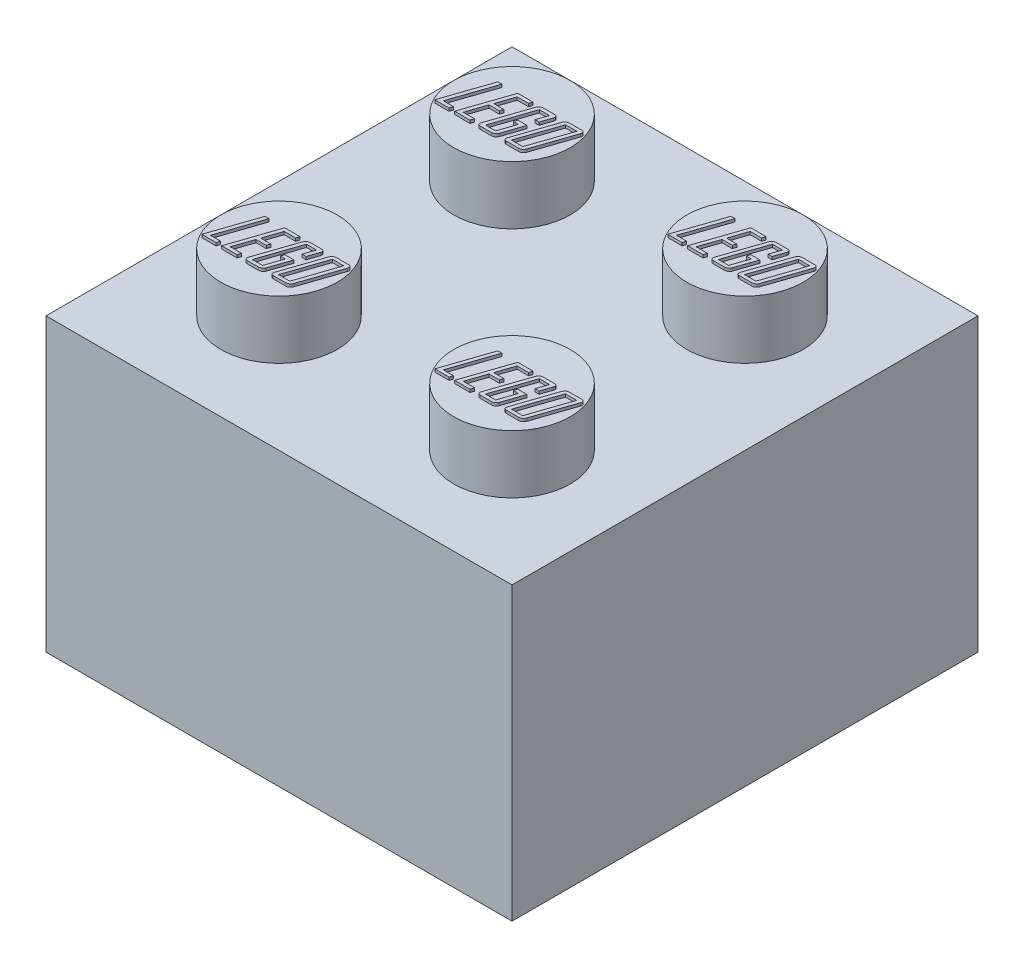
from build123d import *

# Parameters (mm, degrees)
SKETCH1_W           = 16
SKETCH1_H           = 16
BOSS_EXTRUDE1_DEPTH = 10
SKETCH2_R           = 2
BOSS_EXTRUDE2_DEPTH = 2
SHELL1_T            = -1
SKETCH3_R           = 2.7
SKETCH3_R_2         = 1.7
BOSS_EXTRUDE3_DEPTH = 9
BOSS_EXTRUDE4_DEPTH = 0.1
BOSS_EXTRUDE5_DEPTH = 0.1
BOSS_EXTRUDE6_DEPTH = 0.1
BOSS_EXTRUDE7_DEPTH = 0.1


with BuildPart() as part:
    # Sketch1 → Boss-Extrude1 (new body)
    with BuildSketch(Plane(origin=(0, 0, 0), x_dir=(1, 0, 0), z_dir=(0, 1, 0))):
        Rectangle(SKETCH1_W, SKETCH1_H)
    extrude(amount=BOSS_EXTRUDE1_DEPTH)

    # Sketch2 → Boss-Extrude2 (add)
    with BuildSketch(Plane(origin=(0, 10, 0), x_dir=(1, 0, 0), z_dir=(0, 1, 0))):
        with Locations((-4, 4)):
            Circle(SKETCH2_R)
        with Locations((4, 4)):
            Circle(SKETCH2_R)
        with Locations((4, -4)):
            Circle(SKETCH2_R)
        with Locations((-4, -4)):
            Circle(SKETCH2_R)
    extrude(amount=BOSS_EXTRUDE2_DEPTH)

    # Shell1
    shell1_openings = [part.faces().sort_by_distance(p)[0] for p in [
        (0, 0, 0),
    ]]
    offset(amount=SHELL1_T, openings=shell1_openings, kind=Kind.INTERSECTION)

    # Sketch3 → Boss-Extrude3 (add)
    with BuildSketch(Plane.XZ.offset(-9)):
        Circle(SKETCH3_R)
        Circle(SKETCH3_R_2, mode=Mode.SUBTRACT)
    extrude(amount=BOSS_EXTRUDE3_DEPTH)

    # Sketch4 → Boss-Extrude4 (add)
    with BuildSketch(Plane(origin=(0, 12, 0), x_dir=(1, 0, 0), z_dir=(0, 1, 0))):
        Polygon((2.836643841, -5), (2.34945338, -5), (2.899065119, -3.382527669), (3.035478448, -3.382527669), (2.525755428, -4.883074289), (2.87653256, -4.883074289), align=None)
        Polygon((3.557685723, -5), (3.031520025, -5), (3.581131764, -3.382527669), (4.107297462, -3.382527669), (4.067713237, -3.49945338), (3.677960868, -3.49945338), (3.472731887, -4.103569552), (3.823509019, -4.103569552), (3.7836203, -4.220495262), (3.432843168, -4.220495262), (3.207822074, -4.883074289), (3.597574442, -4.883074289), align=None)
        with BuildLine():
            add(Edge.make_bspline(
                [(4.455638642, -4.880638337), (4.452368774, -4.889198537), (4.445935968, -4.906039007), (4.431400617, -4.928878427), (4.413983707, -4.949495674), (4.393365597, -4.967249768), (4.370770278, -4.981865377), (4.346725266, -4.99239163), (4.321581087, -4.998743354), (4.304442691, -4.999578059), (4.295779272, -5)],
                knots=[0, 0, 0, 0, 2.7428e-05, 5.3959e-05, 8.0744e-05, 0.000108157, 0.000135271, 0.00016118, 0.000186585, 0.000212554, 0.000212554, 0.000212554, 0.000212554], degree=3))
            Line((4.295779272, -5), (3.910898808, -5))
            add(Edge.make_bspline(
                [(3.910898808, -5), (3.902740577, -4.999615201), (3.887381648, -4.998890767), (3.866036635, -4.992912418), (3.848483626, -4.982185836), (3.835153343, -4.967265752), (3.826422279, -4.948874865), (3.823289738, -4.927824815), (3.824997164, -4.904590161), (3.829579531, -4.88899469), (3.832034852, -4.880638337)],
                knots=[0, 0, 0, 0, 2.4453e-05, 4.6035e-05, 6.5724e-05, 8.5347e-05, 0.000105232, 0.000125907, 0.00014849, 0.00017456, 0.00017456, 0.00017456, 0.00017456], degree=3))
            Line((3.832034852, -4.880638337), (4.300651176, -3.501889332))
            add(Edge.make_bspline(
                [(4.300651176, -3.501889332), (4.303914387, -3.493323173), (4.310334098, -3.476470978), (4.324929938, -3.453772874), (4.34188589, -3.432921387), (4.362739721, -3.415606921), (4.385336413, -3.400934882), (4.409419102, -3.390130142), (4.434712496, -3.383794141), (4.451848391, -3.38295291), (4.460510547, -3.382527669)],
                knots=[0, 0, 0, 0, 2.7428e-05, 5.3959e-05, 8.0548e-05, 0.000107762, 0.000134876, 0.000161186, 0.000186591, 0.000212561, 0.000212561, 0.000212561, 0.000212561], degree=3))
            Line((4.460510547, -3.382527669), (4.845391011, -3.382527669))
            add(Edge.make_bspline(
                [(4.845391011, -3.382527669), (4.853545932, -3.382919115), (4.868898631, -3.383656061), (4.890337636, -3.389565891), (4.90773007, -3.400587551), (4.920747049, -3.415600123), (4.929548337, -3.433744437), (4.933098786, -3.454675317), (4.931262857, -3.47794065), (4.926699892, -3.493534075), (4.924254967, -3.501889332)],
                knots=[0, 0, 0, 0, 2.4453e-05, 4.6035e-05, 6.5886e-05, 8.5307e-05, 0.000104918, 0.000125643, 0.000148227, 0.000174297, 0.000174297, 0.000174297, 0.000174297], degree=3))
            Line((4.924254967, -3.501889332), (4.799412411, -3.86971813))
            Line((4.799412411, -3.86971813), (4.662999082, -3.86971813))
            Line((4.662999082, -3.86971813), (4.78875512, -3.49945338))
            Line((4.78875512, -3.49945338), (4.437977988, -3.49945338))
            Line((4.437977988, -3.49945338), (3.967839193, -4.883074289))
            Line((3.967839193, -4.883074289), (4.318616325, -4.883074289))
            Line((4.318616325, -4.883074289), (4.517146438, -4.298445736))
            Line((4.517146438, -4.298445736), (4.341757872, -4.298445736))
            Line((4.341757872, -4.298445736), (4.381646591, -4.181520025))
            Line((4.381646591, -4.181520025), (4.693448486, -4.181520025))
            Line((4.693448486, -4.181520025), (4.455638642, -4.880638337))
        make_face()
        with BuildLine():
            add(Edge.make_bspline(
                [(5.391044327, -4.880638337), (5.387774457, -4.889198527), (5.381341647, -4.906038978), (5.366806327, -4.928878538), (5.349389296, -4.94949525), (5.328771648, -4.967251385), (5.306174641, -4.98185953), (5.282044962, -4.992451999), (5.256872957, -4.99868268), (5.239743812, -4.999561089), (5.231184957, -5)],
                knots=[0, 0, 0, 0, 2.7428e-05, 5.3959e-05, 8.0744e-05, 0.000108157, 0.000135271, 0.00016118, 0.00018688, 0.000212546, 0.000212546, 0.000212546, 0.000212546], degree=3))
            Line((5.231184957, -5), (4.807329256, -5))
            add(Edge.make_bspline(
                [(4.807329256, -5), (4.799171025, -4.999615201), (4.783812096, -4.998890767), (4.762467084, -4.992912418), (4.744914074, -4.982185836), (4.731583792, -4.967265752), (4.722852727, -4.948874865), (4.719720186, -4.927824815), (4.721427612, -4.904590161), (4.72600998, -4.88899469), (4.7284653, -4.880638337)],
                knots=[0, 0, 0, 0, 2.4453e-05, 4.6035e-05, 6.5724e-05, 8.5347e-05, 0.000105232, 0.000125907, 0.00014849, 0.00017456, 0.00017456, 0.00017456, 0.00017456], degree=3))
            Line((4.7284653, -4.880638337), (5.197081625, -3.501889332))
            add(Edge.make_bspline(
                [(5.197081625, -3.501889332), (5.200344836, -3.493323173), (5.206764546, -3.476470978), (5.221360387, -3.453772874), (5.238316338, -3.432921387), (5.259170169, -3.415606921), (5.281766862, -3.400934882), (5.30584955, -3.390130142), (5.331142944, -3.383794141), (5.34827884, -3.38295291), (5.356940995, -3.382527669)],
                knots=[0, 0, 0, 0, 2.7428e-05, 5.3959e-05, 8.0548e-05, 0.000107762, 0.000134876, 0.000161186, 0.000186591, 0.000212561, 0.000212561, 0.000212561, 0.000212561], degree=3))
            Line((5.356940995, -3.382527669), (5.780796696, -3.382527669))
            add(Edge.make_bspline(
                [(5.780796696, -3.382527669), (5.788953468, -3.382906904), (5.804212263, -3.383616336), (5.825536749, -3.389620389), (5.842822584, -3.400679729), (5.856180513, -3.415488298), (5.864937695, -3.433758785), (5.868509352, -3.454671028), (5.86666705, -3.477941962), (5.862105056, -3.493534533), (5.859660652, -3.501889332)],
                knots=[0, 0, 0, 0, 2.4453e-05, 4.5743e-05, 6.5594e-05, 8.5217e-05, 0.000104827, 0.000125553, 0.000148137, 0.000174207, 0.000174207, 0.000174207, 0.000174207], degree=3))
            Line((5.859660652, -3.501889332), (5.391044327, -4.880638337))
        make_face()
        Polygon((5.25402201, -4.883074289), (5.724160805, -3.49945338), (5.334408436, -3.49945338), (4.864269641, -4.883074289), align=None, mode=Mode.SUBTRACT)
    extrude(amount=BOSS_EXTRUDE4_DEPTH)

    # Sketch6 → Boss-Extrude5 (add)
    with BuildSketch(Plane(origin=(0, 12, 0), x_dir=(1, 0, 0), z_dir=(0, 1, 0))):
        Polygon((-5.163356159, -5), (-5.65054662, -5), (-5.100934881, -3.382527669), (-4.964521552, -3.382527669), (-5.474244572, -4.883074289), (-5.12346744, -4.883074289), align=None)
        Polygon((-4.442314277, -5), (-4.968479975, -5), (-4.418868236, -3.382527669), (-3.892702538, -3.382527669), (-3.932286763, -3.49945338), (-4.322039132, -3.49945338), (-4.527268113, -4.103569552), (-4.176490981, -4.103569552), (-4.2163797, -4.220495262), (-4.567156832, -4.220495262), (-4.792177926, -4.883074289), (-4.402425558, -4.883074289), align=None)
        with BuildLine():
            add(Edge.make_bspline(
                [(-3.544361358, -4.880638337), (-3.547631226, -4.889198537), (-3.554064032, -4.906039007), (-3.568599383, -4.928878427), (-3.586016293, -4.949495674), (-3.606634403, -4.967249768), (-3.629229722, -4.981865377), (-3.653274734, -4.99239163), (-3.678418913, -4.998743354), (-3.695557309, -4.999578059), (-3.704220728, -5)],
                knots=[0, 0, 0, 0, 2.7428e-05, 5.3959e-05, 8.0744e-05, 0.000108157, 0.000135271, 0.00016118, 0.000186585, 0.000212554, 0.000212554, 0.000212554, 0.000212554], degree=3))
            Line((-3.704220728, -5), (-4.089101192, -5))
            add(Edge.make_bspline(
                [(-4.089101192, -5), (-4.097259423, -4.999615201), (-4.112618352, -4.998890767), (-4.133963365, -4.992912418), (-4.151516374, -4.982185836), (-4.164846657, -4.967265752), (-4.173577721, -4.948874865), (-4.176710262, -4.927824815), (-4.175002836, -4.904590161), (-4.170420469, -4.88899469), (-4.167965148, -4.880638337)],
                knots=[0, 0, 0, 0, 2.4453e-05, 4.6035e-05, 6.5724e-05, 8.5347e-05, 0.000105232, 0.000125907, 0.00014849, 0.00017456, 0.00017456, 0.00017456, 0.00017456], degree=3))
            Line((-4.167965148, -4.880638337), (-3.699348824, -3.501889332))
            add(Edge.make_bspline(
                [(-3.699348824, -3.501889332), (-3.696085613, -3.493323173), (-3.689665902, -3.476470978), (-3.675070062, -3.453772874), (-3.65811411, -3.432921387), (-3.637260279, -3.415606921), (-3.614663587, -3.400934882), (-3.590580898, -3.390130142), (-3.565287504, -3.383794141), (-3.548151609, -3.38295291), (-3.539489453, -3.382527669)],
                knots=[0, 0, 0, 0, 2.7428e-05, 5.3959e-05, 8.0548e-05, 0.000107762, 0.000134876, 0.000161186, 0.000186591, 0.000212561, 0.000212561, 0.000212561, 0.000212561], degree=3))
            Line((-3.539489453, -3.382527669), (-3.154608989, -3.382527669))
            add(Edge.make_bspline(
                [(-3.154608989, -3.382527669), (-3.146454068, -3.382919115), (-3.131101369, -3.383656061), (-3.109662364, -3.389565891), (-3.09226993, -3.400587551), (-3.079252951, -3.415600123), (-3.070451663, -3.433744437), (-3.066901214, -3.454675317), (-3.068737143, -3.47794065), (-3.073300108, -3.493534075), (-3.075745033, -3.501889332)],
                knots=[0, 0, 0, 0, 2.4453e-05, 4.6035e-05, 6.5886e-05, 8.5307e-05, 0.000104918, 0.000125643, 0.000148227, 0.000174297, 0.000174297, 0.000174297, 0.000174297], degree=3))
            Line((-3.075745033, -3.501889332), (-3.200587589, -3.86971813))
            Line((-3.200587589, -3.86971813), (-3.337000918, -3.86971813))
            Line((-3.337000918, -3.86971813), (-3.21124488, -3.49945338))
            Line((-3.21124488, -3.49945338), (-3.562022012, -3.49945338))
            Line((-3.562022012, -3.49945338), (-4.032160807, -4.883074289))
            Line((-4.032160807, -4.883074289), (-3.681383675, -4.883074289))
            Line((-3.681383675, -4.883074289), (-3.482853562, -4.298445736))
            Line((-3.482853562, -4.298445736), (-3.658242128, -4.298445736))
            Line((-3.658242128, -4.298445736), (-3.618353409, -4.181520025))
            Line((-3.618353409, -4.181520025), (-3.306551514, -4.181520025))
            Line((-3.306551514, -4.181520025), (-3.544361358, -4.880638337))
        make_face()
        with BuildLine():
            add(Edge.make_bspline(
                [(-2.608955673, -4.880638337), (-2.612225543, -4.889198527), (-2.618658353, -4.906038978), (-2.633193673, -4.928878538), (-2.650610704, -4.94949525), (-2.671228352, -4.967251385), (-2.693825359, -4.98185953), (-2.717955038, -4.992451999), (-2.743127043, -4.99868268), (-2.760256188, -4.999561089), (-2.768815043, -5)],
                knots=[0, 0, 0, 0, 2.7428e-05, 5.3959e-05, 8.0744e-05, 0.000108157, 0.000135271, 0.00016118, 0.00018688, 0.000212546, 0.000212546, 0.000212546, 0.000212546], degree=3))
            Line((-2.768815043, -5), (-3.192670744, -5))
            add(Edge.make_bspline(
                [(-3.192670744, -5), (-3.200828975, -4.999615201), (-3.216187904, -4.998890767), (-3.237532916, -4.992912418), (-3.255085926, -4.982185836), (-3.268416208, -4.967265752), (-3.277147273, -4.948874865), (-3.280279814, -4.927824815), (-3.278572388, -4.904590161), (-3.27399002, -4.88899469), (-3.2715347, -4.880638337)],
                knots=[0, 0, 0, 0, 2.4453e-05, 4.6035e-05, 6.5724e-05, 8.5347e-05, 0.000105232, 0.000125907, 0.00014849, 0.00017456, 0.00017456, 0.00017456, 0.00017456], degree=3))
            Line((-3.2715347, -4.880638337), (-2.802918375, -3.501889332))
            add(Edge.make_bspline(
                [(-2.802918375, -3.501889332), (-2.799655164, -3.493323173), (-2.793235454, -3.476470978), (-2.778639613, -3.453772874), (-2.761683662, -3.432921387), (-2.740829831, -3.415606921), (-2.718233138, -3.400934882), (-2.69415045, -3.390130142), (-2.668857056, -3.383794141), (-2.65172116, -3.38295291), (-2.643059005, -3.382527669)],
                knots=[0, 0, 0, 0, 2.7428e-05, 5.3959e-05, 8.0548e-05, 0.000107762, 0.000134876, 0.000161186, 0.000186591, 0.000212561, 0.000212561, 0.000212561, 0.000212561], degree=3))
            Line((-2.643059005, -3.382527669), (-2.219203304, -3.382527669))
            add(Edge.make_bspline(
                [(-2.219203304, -3.382527669), (-2.211046532, -3.382906904), (-2.195787737, -3.383616336), (-2.174463251, -3.389620389), (-2.157177416, -3.400679729), (-2.143819487, -3.415488298), (-2.135062305, -3.433758785), (-2.131490648, -3.454671028), (-2.13333295, -3.477941962), (-2.137894944, -3.493534533), (-2.140339348, -3.501889332)],
                knots=[0, 0, 0, 0, 2.4453e-05, 4.5743e-05, 6.5594e-05, 8.5217e-05, 0.000104827, 0.000125553, 0.000148137, 0.000174207, 0.000174207, 0.000174207, 0.000174207], degree=3))
            Line((-2.140339348, -3.501889332), (-2.608955673, -4.880638337))
        make_face()
        Polygon((-2.74597799, -4.883074289), (-2.275839195, -3.49945338), (-2.665591564, -3.49945338), (-3.135730359, -4.883074289), align=None, mode=Mode.SUBTRACT)
    extrude(amount=BOSS_EXTRUDE5_DEPTH)

    # Sketch7 → Boss-Extrude6 (add)
    with BuildSketch(Plane(origin=(0, 12, 0), x_dir=(1, 0, 0), z_dir=(0, 1, 0))):
        Polygon((-5.163356159, 3), (-5.65054662, 3), (-5.100934881, 4.617472331), (-4.964521552, 4.617472331), (-5.474244572, 3.116925711), (-5.12346744, 3.116925711), align=None)
        Polygon((-4.442314277, 3), (-4.968479975, 3), (-4.418868236, 4.617472331), (-3.892702538, 4.617472331), (-3.932286763, 4.50054662), (-4.322039132, 4.50054662), (-4.527268113, 3.896430448), (-4.176490981, 3.896430448), (-4.2163797, 3.779504738), (-4.567156832, 3.779504738), (-4.792177926, 3.116925711), (-4.402425558, 3.116925711), align=None)
        with BuildLine():
            add(Edge.make_bspline(
                [(-3.544361358, 3.119361663), (-3.547631226, 3.110801463), (-3.554064032, 3.093960993), (-3.568599383, 3.071121573), (-3.586016293, 3.050504326), (-3.606634403, 3.032750232), (-3.629229722, 3.018134623), (-3.653274734, 3.00760837), (-3.678418913, 3.001256646), (-3.695557309, 3.000421941), (-3.704220728, 3)],
                knots=[0, 0, 0, 0, 2.7428e-05, 5.3959e-05, 8.0744e-05, 0.000108157, 0.000135271, 0.00016118, 0.000186585, 0.000212554, 0.000212554, 0.000212554, 0.000212554], degree=3))
            Line((-3.704220728, 3), (-4.089101192, 3))
            add(Edge.make_bspline(
                [(-4.089101192, 3), (-4.097259423, 3.000384799), (-4.112618352, 3.001109233), (-4.133963365, 3.007087582), (-4.151516374, 3.017814164), (-4.164846657, 3.032734248), (-4.173577721, 3.051125135), (-4.176710262, 3.072175185), (-4.175002836, 3.095409839), (-4.170420469, 3.11100531), (-4.167965148, 3.119361663)],
                knots=[0, 0, 0, 0, 2.4453e-05, 4.6035e-05, 6.5724e-05, 8.5347e-05, 0.000105232, 0.000125907, 0.00014849, 0.00017456, 0.00017456, 0.00017456, 0.00017456], degree=3))
            Line((-4.167965148, 3.119361663), (-3.699348824, 4.498110668))
            add(Edge.make_bspline(
                [(-3.699348824, 4.498110668), (-3.696085613, 4.506676827), (-3.689665902, 4.523529022), (-3.675070062, 4.546227126), (-3.65811411, 4.567078613), (-3.637260279, 4.584393079), (-3.614663587, 4.599065118), (-3.590580898, 4.609869858), (-3.565287504, 4.616205859), (-3.548151609, 4.61704709), (-3.539489453, 4.617472331)],
                knots=[0, 0, 0, 0, 2.7428e-05, 5.3959e-05, 8.0548e-05, 0.000107762, 0.000134876, 0.000161186, 0.000186591, 0.000212561, 0.000212561, 0.000212561, 0.000212561], degree=3))
            Line((-3.539489453, 4.617472331), (-3.154608989, 4.617472331))
            add(Edge.make_bspline(
                [(-3.154608989, 4.617472331), (-3.146454068, 4.617080885), (-3.131101369, 4.616343939), (-3.109662364, 4.610434109), (-3.09226993, 4.599412449), (-3.079252951, 4.584399877), (-3.070451663, 4.566255563), (-3.066901214, 4.545324683), (-3.068737143, 4.52205935), (-3.073300108, 4.506465925), (-3.075745033, 4.498110668)],
                knots=[0, 0, 0, 0, 2.4453e-05, 4.6035e-05, 6.5886e-05, 8.5307e-05, 0.000104918, 0.000125643, 0.000148227, 0.000174297, 0.000174297, 0.000174297, 0.000174297], degree=3))
            Line((-3.075745033, 4.498110668), (-3.200587589, 4.13028187))
            Line((-3.200587589, 4.13028187), (-3.337000918, 4.13028187))
            Line((-3.337000918, 4.13028187), (-3.21124488, 4.50054662))
            Line((-3.21124488, 4.50054662), (-3.562022012, 4.50054662))
            Line((-3.562022012, 4.50054662), (-4.032160807, 3.116925711))
            Line((-4.032160807, 3.116925711), (-3.681383675, 3.116925711))
            Line((-3.681383675, 3.116925711), (-3.482853562, 3.701554264))
            Line((-3.482853562, 3.701554264), (-3.658242128, 3.701554264))
            Line((-3.658242128, 3.701554264), (-3.618353409, 3.818479975))
            Line((-3.618353409, 3.818479975), (-3.306551514, 3.818479975))
            Line((-3.306551514, 3.818479975), (-3.544361358, 3.119361663))
        make_face()
        with BuildLine():
            add(Edge.make_bspline(
                [(-2.608955673, 3.119361663), (-2.612225543, 3.110801473), (-2.618658353, 3.093961022), (-2.633193673, 3.071121462), (-2.650610704, 3.05050475), (-2.671228352, 3.032748615), (-2.693825359, 3.01814047), (-2.717955038, 3.007548001), (-2.743127043, 3.00131732), (-2.760256188, 3.000438911), (-2.768815043, 3)],
                knots=[0, 0, 0, 0, 2.7428e-05, 5.3959e-05, 8.0744e-05, 0.000108157, 0.000135271, 0.00016118, 0.00018688, 0.000212546, 0.000212546, 0.000212546, 0.000212546], degree=3))
            Line((-2.768815043, 3), (-3.192670744, 3))
            add(Edge.make_bspline(
                [(-3.192670744, 3), (-3.200828975, 3.000384799), (-3.216187904, 3.001109233), (-3.237532916, 3.007087582), (-3.255085926, 3.017814164), (-3.268416208, 3.032734248), (-3.277147273, 3.051125135), (-3.280279814, 3.072175185), (-3.278572388, 3.095409839), (-3.27399002, 3.11100531), (-3.2715347, 3.119361663)],
                knots=[0, 0, 0, 0, 2.4453e-05, 4.6035e-05, 6.5724e-05, 8.5347e-05, 0.000105232, 0.000125907, 0.00014849, 0.00017456, 0.00017456, 0.00017456, 0.00017456], degree=3))
            Line((-3.2715347, 3.119361663), (-2.802918375, 4.498110668))
            add(Edge.make_bspline(
                [(-2.802918375, 4.498110668), (-2.799655164, 4.506676827), (-2.793235454, 4.523529022), (-2.778639613, 4.546227126), (-2.761683662, 4.567078613), (-2.740829831, 4.584393079), (-2.718233138, 4.599065118), (-2.69415045, 4.609869858), (-2.668857056, 4.616205859), (-2.65172116, 4.61704709), (-2.643059005, 4.617472331)],
                knots=[0, 0, 0, 0, 2.7428e-05, 5.3959e-05, 8.0548e-05, 0.000107762, 0.000134876, 0.000161186, 0.000186591, 0.000212561, 0.000212561, 0.000212561, 0.000212561], degree=3))
            Line((-2.643059005, 4.617472331), (-2.219203304, 4.617472331))
            add(Edge.make_bspline(
                [(-2.219203304, 4.617472331), (-2.211046532, 4.617093096), (-2.195787737, 4.616383664), (-2.174463251, 4.610379611), (-2.157177416, 4.599320271), (-2.143819487, 4.584511702), (-2.135062305, 4.566241215), (-2.131490648, 4.545328972), (-2.13333295, 4.522058038), (-2.137894944, 4.506465467), (-2.140339348, 4.498110668)],
                knots=[0, 0, 0, 0, 2.4453e-05, 4.5743e-05, 6.5594e-05, 8.5217e-05, 0.000104827, 0.000125553, 0.000148137, 0.000174207, 0.000174207, 0.000174207, 0.000174207], degree=3))
            Line((-2.140339348, 4.498110668), (-2.608955673, 3.119361663))
        make_face()
        Polygon((-2.74597799, 3.116925711), (-2.275839195, 4.50054662), (-2.665591564, 4.50054662), (-3.135730359, 3.116925711), align=None, mode=Mode.SUBTRACT)
    extrude(amount=BOSS_EXTRUDE6_DEPTH)

    # Sketch8 → Boss-Extrude7 (add)
    with BuildSketch(Plane(origin=(0, 12, 0), x_dir=(1, 0, 0), z_dir=(0, 1, 0))):
        Polygon((2.836643841, 3), (2.34945338, 3), (2.899065119, 4.617472331), (3.035478448, 4.617472331), (2.525755428, 3.116925711), (2.87653256, 3.116925711), align=None)
        Polygon((3.557685723, 3), (3.031520025, 3), (3.581131764, 4.617472331), (4.107297462, 4.617472331), (4.067713237, 4.50054662), (3.677960868, 4.50054662), (3.472731887, 3.896430448), (3.823509019, 3.896430448), (3.7836203, 3.779504738), (3.432843168, 3.779504738), (3.207822074, 3.116925711), (3.597574442, 3.116925711), align=None)
        with BuildLine():
            add(Edge.make_bspline(
                [(4.455638642, 3.119361663), (4.452368774, 3.110801463), (4.445935968, 3.093960993), (4.431400617, 3.071121573), (4.413983707, 3.050504326), (4.393365597, 3.032750232), (4.370770278, 3.018134623), (4.346725266, 3.00760837), (4.321581087, 3.001256646), (4.304442691, 3.000421941), (4.295779272, 3)],
                knots=[0, 0, 0, 0, 2.7428e-05, 5.3959e-05, 8.0744e-05, 0.000108157, 0.000135271, 0.00016118, 0.000186585, 0.000212554, 0.000212554, 0.000212554, 0.000212554], degree=3))
            Line((4.295779272, 3), (3.910898808, 3))
            add(Edge.make_bspline(
                [(3.910898808, 3), (3.902740577, 3.000384799), (3.887381648, 3.001109233), (3.866036635, 3.007087582), (3.848483626, 3.017814164), (3.835153343, 3.032734248), (3.826422279, 3.051125135), (3.823289738, 3.072175185), (3.824997164, 3.095409839), (3.829579531, 3.11100531), (3.832034852, 3.119361663)],
                knots=[0, 0, 0, 0, 2.4453e-05, 4.6035e-05, 6.5724e-05, 8.5347e-05, 0.000105232, 0.000125907, 0.00014849, 0.00017456, 0.00017456, 0.00017456, 0.00017456], degree=3))
            Line((3.832034852, 3.119361663), (4.300651176, 4.498110668))
            add(Edge.make_bspline(
                [(4.300651176, 4.498110668), (4.303914387, 4.506676827), (4.310334098, 4.523529022), (4.324929938, 4.546227126), (4.34188589, 4.567078613), (4.362739721, 4.584393079), (4.385336413, 4.599065118), (4.409419102, 4.609869858), (4.434712496, 4.616205859), (4.451848391, 4.61704709), (4.460510547, 4.617472331)],
                knots=[0, 0, 0, 0, 2.7428e-05, 5.3959e-05, 8.0548e-05, 0.000107762, 0.000134876, 0.000161186, 0.000186591, 0.000212561, 0.000212561, 0.000212561, 0.000212561], degree=3))
            Line((4.460510547, 4.617472331), (4.845391011, 4.617472331))
            add(Edge.make_bspline(
                [(4.845391011, 4.617472331), (4.853545932, 4.617080885), (4.868898631, 4.616343939), (4.890337636, 4.610434109), (4.90773007, 4.599412449), (4.920747049, 4.584399877), (4.929548337, 4.566255563), (4.933098786, 4.545324683), (4.931262857, 4.52205935), (4.926699892, 4.506465925), (4.924254967, 4.498110668)],
                knots=[0, 0, 0, 0, 2.4453e-05, 4.6035e-05, 6.5886e-05, 8.5307e-05, 0.000104918, 0.000125643, 0.000148227, 0.000174297, 0.000174297, 0.000174297, 0.000174297], degree=3))
            Line((4.924254967, 4.498110668), (4.799412411, 4.13028187))
            Line((4.799412411, 4.13028187), (4.662999082, 4.13028187))
            Line((4.662999082, 4.13028187), (4.78875512, 4.50054662))
            Line((4.78875512, 4.50054662), (4.437977988, 4.50054662))
            Line((4.437977988, 4.50054662), (3.967839193, 3.116925711))
            Line((3.967839193, 3.116925711), (4.318616325, 3.116925711))
            Line((4.318616325, 3.116925711), (4.517146438, 3.701554264))
            Line((4.517146438, 3.701554264), (4.341757872, 3.701554264))
            Line((4.341757872, 3.701554264), (4.381646591, 3.818479975))
            Line((4.381646591, 3.818479975), (4.693448486, 3.818479975))
            Line((4.693448486, 3.818479975), (4.455638642, 3.119361663))
        make_face()
        with BuildLine():
            add(Edge.make_bspline(
                [(5.391044327, 3.119361663), (5.387774457, 3.110801473), (5.381341647, 3.093961022), (5.366806327, 3.071121462), (5.349389296, 3.05050475), (5.328771648, 3.032748615), (5.306174641, 3.01814047), (5.282044962, 3.007548001), (5.256872957, 3.00131732), (5.239743812, 3.000438911), (5.231184957, 3)],
                knots=[0, 0, 0, 0, 2.7428e-05, 5.3959e-05, 8.0744e-05, 0.000108157, 0.000135271, 0.00016118, 0.00018688, 0.000212546, 0.000212546, 0.000212546, 0.000212546], degree=3))
            Line((5.231184957, 3), (4.807329256, 3))
            add(Edge.make_bspline(
                [(4.807329256, 3), (4.799171025, 3.000384799), (4.783812096, 3.001109233), (4.762467084, 3.007087582), (4.744914074, 3.017814164), (4.731583792, 3.032734248), (4.722852727, 3.051125135), (4.719720186, 3.072175185), (4.721427612, 3.095409839), (4.72600998, 3.11100531), (4.7284653, 3.119361663)],
                knots=[0, 0, 0, 0, 2.4453e-05, 4.6035e-05, 6.5724e-05, 8.5347e-05, 0.000105232, 0.000125907, 0.00014849, 0.00017456, 0.00017456, 0.00017456, 0.00017456], degree=3))
            Line((4.7284653, 3.119361663), (5.197081625, 4.498110668))
            add(Edge.make_bspline(
                [(5.197081625, 4.498110668), (5.200344836, 4.506676827), (5.206764546, 4.523529022), (5.221360387, 4.546227126), (5.238316338, 4.567078613), (5.259170169, 4.584393079), (5.281766862, 4.599065118), (5.30584955, 4.609869858), (5.331142944, 4.616205859), (5.34827884, 4.61704709), (5.356940995, 4.617472331)],
                knots=[0, 0, 0, 0, 2.7428e-05, 5.3959e-05, 8.0548e-05, 0.000107762, 0.000134876, 0.000161186, 0.000186591, 0.000212561, 0.000212561, 0.000212561, 0.000212561], degree=3))
            Line((5.356940995, 4.617472331), (5.780796696, 4.617472331))
            add(Edge.make_bspline(
                [(5.780796696, 4.617472331), (5.788953468, 4.617093096), (5.804212263, 4.616383664), (5.825536749, 4.610379611), (5.842822584, 4.599320271), (5.856180513, 4.584511702), (5.864937695, 4.566241215), (5.868509352, 4.545328972), (5.86666705, 4.522058038), (5.862105056, 4.506465467), (5.859660652, 4.498110668)],
                knots=[0, 0, 0, 0, 2.4453e-05, 4.5743e-05, 6.5594e-05, 8.5217e-05, 0.000104827, 0.000125553, 0.000148137, 0.000174207, 0.000174207, 0.000174207, 0.000174207], degree=3))
            Line((5.859660652, 4.498110668), (5.391044327, 3.119361663))
        make_face()
        Polygon((5.25402201, 3.116925711), (5.724160805, 4.50054662), (5.334408436, 4.50054662), (4.864269641, 3.116925711), align=None, mode=Mode.SUBTRACT)
    extrude(amount=BOSS_EXTRUDE7_DEPTH)


solid = part.part
